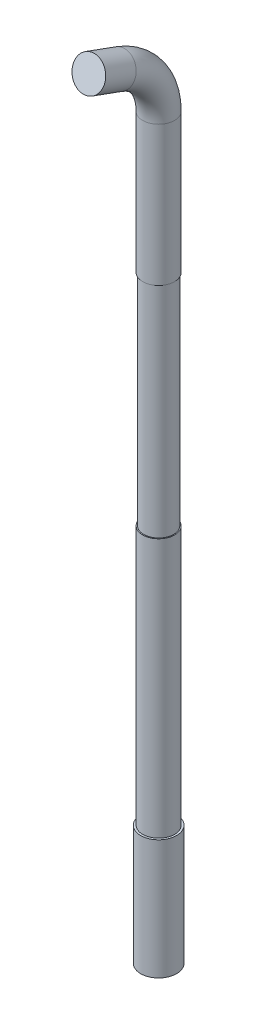
from build123d import *

# Parameters (mm, degrees)
SKETCH2_R         = 0.8
SKETCH4_R         = 0.9
EXTRUDE1_DEPTH    = 6
SKETCH5_OUTSIDE_W = 12.086
SKETCH5_OUTSIDE_H = 14.96
SKETCH5_OUTSIDE_R = 0.75
EXTRUDE3_DEPTH    = 11


with BuildPart() as part:
    # Sweep1: sweep along a path in Sketch1
    with BuildLine(Plane(origin=(0, 0, 0), x_dir=(0, 0, -1), z_dir=(1, 0, 0))) as sweep1_path:
        Line((9, 0), (9, 37))
        ThreePointArc((9, 37), (8.457456133, 38.720729309), (7.02606043, 39.819077862))
        Line((7.02606043, 39.819077862), (5.5, 40.374518435))
    # Sketch2 → Sweep1 (sweep)
    with BuildSketch(Plane(origin=(0, 0, 0), x_dir=(1, 0, 0), z_dir=(0, 1, 0))):
        with Locations((0, 9)):
            Circle(SKETCH2_R)
    sweep(path=sweep1_path.line)

    # Sketch4 → Extrude1 (add)
    with BuildSketch(Plane(origin=(0, 0, 0), x_dir=(1, 0, 0), z_dir=(0, 1, 0))):
        with Locations((0, 9)):
            Circle(SKETCH4_R)
    extrude(amount=EXTRUDE1_DEPTH)

    # Sketch5 outside → Extrude3 (cut)
    with BuildSketch(Plane(origin=(0, 19, 0), x_dir=(-1, 0, 0), z_dir=(0, 1, 0))):
        with Locations((0, -7.563)):
            Rectangle(SKETCH5_OUTSIDE_W, SKETCH5_OUTSIDE_H)
        with Locations((0, -9)):
            Circle(SKETCH5_OUTSIDE_R, mode=Mode.SUBTRACT)
    extrude(amount=EXTRUDE3_DEPTH, mode=Mode.SUBTRACT)


solid = part.part
